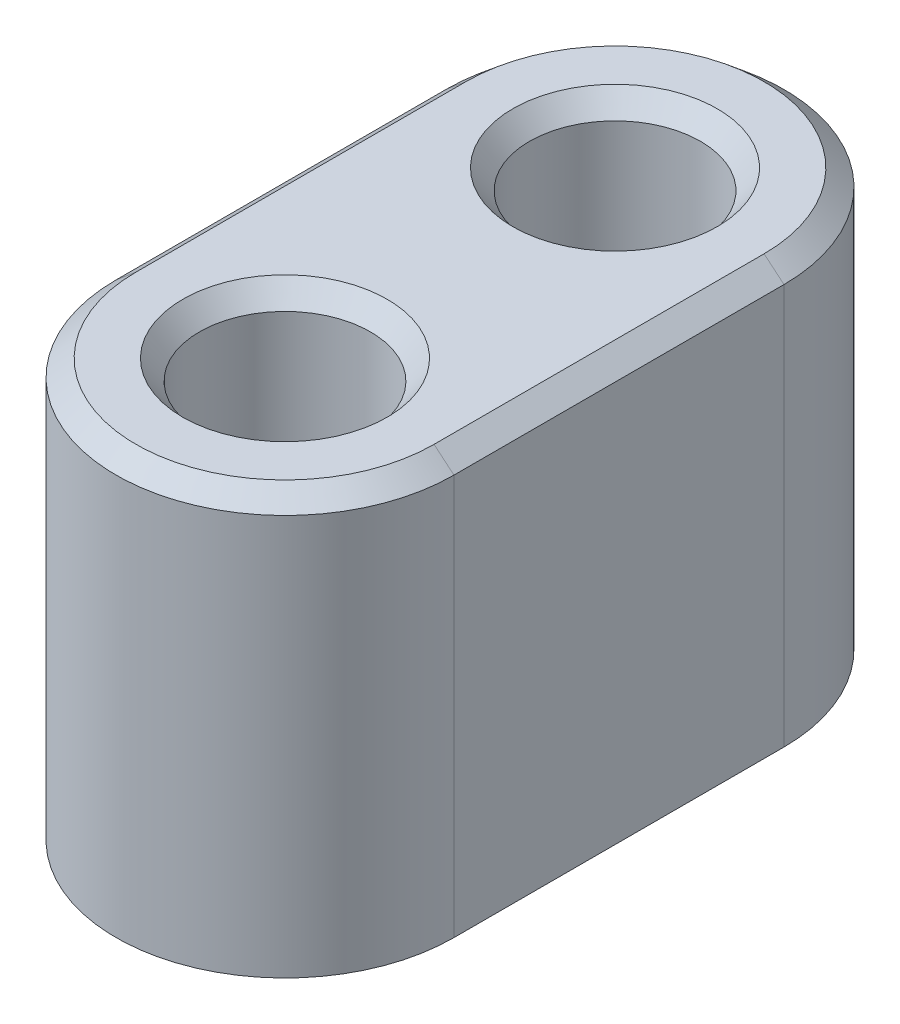
from build123d import *
from OCP.BRepFilletAPI import BRepFilletAPI_MakeChamfer

# Parameters (mm, degrees)
SKETCH1_R           = 2.05
BOSS_EXTRUDE1_DEPTH = 10
CHAMFER1_SIZE       = 0.4
CHAMFER1_SIZE2      = 0.476701437


with BuildPart() as part:
    # Sketch1 → Boss-Extrude1 (new body)
    with BuildSketch(Plane(origin=(0, 0, 0), x_dir=(1, 0, 0), z_dir=(0, 1, 0))):
        with BuildLine():
            Line((-4.05, -3.955), (-4.05, 3.955))
            ThreePointArc((-4.05, 3.955), (0, 8.005), (4.05, 3.955))
            Line((4.05, 3.955), (4.05, -3.955))
            ThreePointArc((4.05, -3.955), (0, -8.005), (-4.05, -3.955))
        make_face()
        with Locations(Location((0, 3.955, 0), (0, 0, 270))):
            Circle(SKETCH1_R, mode=Mode.SUBTRACT)
        with Locations(Location((0, -3.955, 0), (0, 0, 270))):
            Circle(SKETCH1_R, mode=Mode.SUBTRACT)
    extrude(amount=BOSS_EXTRUDE1_DEPTH)

    # Chamfer1: one chamfer whose edges measure the first distance from different faces: ONE call of the kernel's chamfer builder (chamfer() names one face for all edges)
    chamfer1_edges_1 = [part.edges().sort_by_distance(p)[0] for p in [
        (0, 0, -6.005),
    ]]
    chamfer1_side_1 = [part.faces().sort_by_distance(p)[0] for p in [
        (0, 5, -6.005),
    ]]
    chamfer1_edges_2 = [part.edges().sort_by_distance(p)[0] for p in [
        (0, 10, -6.005),
        (0, 10, 1.905),
    ]]
    chamfer1_side_2 = [part.faces().sort_by_distance(p)[0] for p in [
        (0, 10, 0),
    ]]
    chamfer1_edges_3 = [part.edges().sort_by_distance(p)[0] for p in [
        (0, 10, -8.005),
    ]]
    chamfer1_side_3 = [part.faces().sort_by_distance(p)[0] for p in [
        (0, 5, -8.005),
    ]]
    chamfer1_edges_4 = [part.edges().sort_by_distance(p)[0] for p in [
        (0, 0, 1.905),
    ]]
    chamfer1_side_4 = [part.faces().sort_by_distance(p)[0] for p in [
        (0, 5, 1.905),
    ]]
    chamfer1_edges_5 = [part.edges().sort_by_distance(p)[0] for p in [
        (-4.05, 10, 0),
    ]]
    chamfer1_side_5 = [part.faces().sort_by_distance(p)[0] for p in [
        (-4.05, 5, 0),
    ]]
    chamfer1_edges_6 = [part.edges().sort_by_distance(p)[0] for p in [
        (0, 10, 8.005),
    ]]
    chamfer1_side_6 = [part.faces().sort_by_distance(p)[0] for p in [
        (0, 5, 8.005),
    ]]
    chamfer1_edges_7 = [part.edges().sort_by_distance(p)[0] for p in [
        (4.05, 10, 0),
    ]]
    chamfer1_side_7 = [part.faces().sort_by_distance(p)[0] for p in [
        (4.05, 5, 0),
    ]]
    chamfer1 = BRepFilletAPI_MakeChamfer(part.part.solid().wrapped)
    for e in chamfer1_edges_1:
        chamfer1.Add(CHAMFER1_SIZE, CHAMFER1_SIZE2, e.wrapped, chamfer1_side_1[0].wrapped)  # the first distance lies on this face
    for e in chamfer1_edges_2:
        chamfer1.Add(CHAMFER1_SIZE, CHAMFER1_SIZE2, e.wrapped, chamfer1_side_2[0].wrapped)  # the first distance lies on this face
    for e in chamfer1_edges_3:
        chamfer1.Add(CHAMFER1_SIZE, CHAMFER1_SIZE2, e.wrapped, chamfer1_side_3[0].wrapped)  # the first distance lies on this face
    for e in chamfer1_edges_4:
        chamfer1.Add(CHAMFER1_SIZE, CHAMFER1_SIZE2, e.wrapped, chamfer1_side_4[0].wrapped)  # the first distance lies on this face
    for e in chamfer1_edges_5:
        chamfer1.Add(CHAMFER1_SIZE, CHAMFER1_SIZE2, e.wrapped, chamfer1_side_5[0].wrapped)  # the first distance lies on this face
    for e in chamfer1_edges_6:
        chamfer1.Add(CHAMFER1_SIZE, CHAMFER1_SIZE2, e.wrapped, chamfer1_side_6[0].wrapped)  # the first distance lies on this face
    for e in chamfer1_edges_7:
        chamfer1.Add(CHAMFER1_SIZE, CHAMFER1_SIZE2, e.wrapped, chamfer1_side_7[0].wrapped)  # the first distance lies on this face
    add(Compound.cast(chamfer1.Shape()), mode=Mode.REPLACE)


solid = part.part
